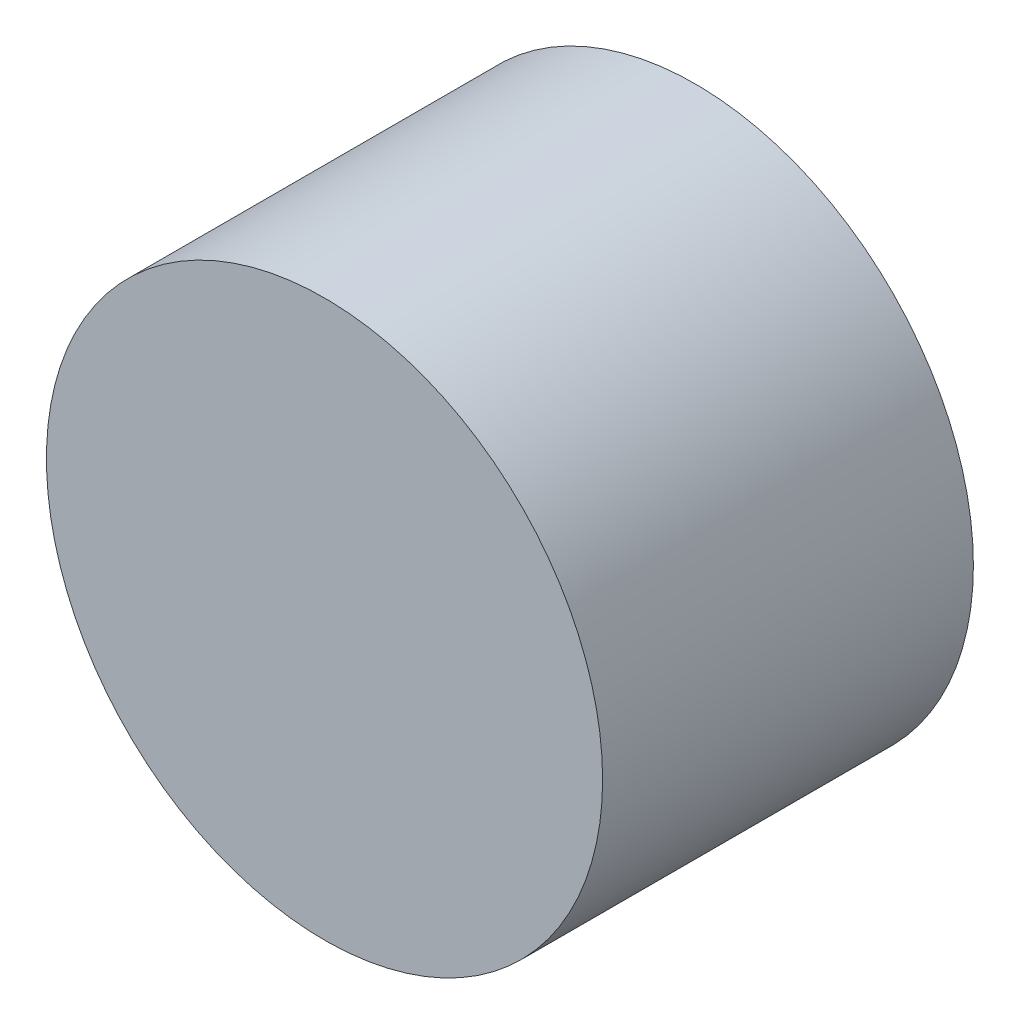
from build123d import *

# Parameters (mm, degrees)
ESQUISSE1_R        = 75
BOSS_EXTRU_1_DEPTH = 100


with BuildPart() as part:
    # Esquisse1 → Boss.-Extru.1 (new body)
    with BuildSketch(Plane.XY):
        Circle(ESQUISSE1_R)
    extrude(amount=BOSS_EXTRU_1_DEPTH)


solid = part.part
